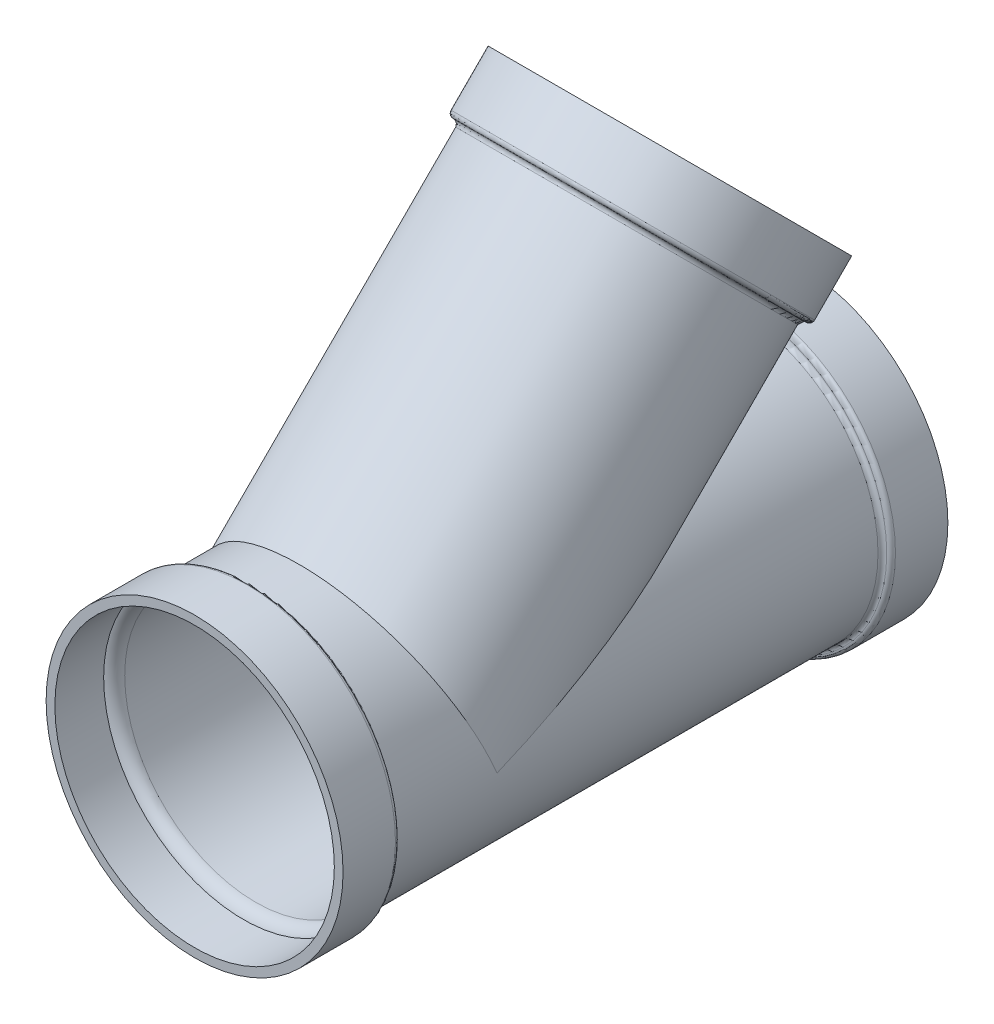
from build123d import *


with BuildPart() as part:
    # Sketch1 → Revolve1 (revolve)
    with BuildSketch(Plane(origin=(0, 0, 0), x_dir=(0, 0, -1), z_dir=(1, 0, 0)), mode=Mode.PRIVATE) as revolve1_sk:
        with BuildLine():
            Line((-439.7375, 215.9), (-363.5375, 215.9))
            ThreePointArc((-363.5375, 215.9), (-359.047371939, 214.040128061), (-357.1875, 209.55))
            ThreePointArc((-357.1875, 209.55), (-355.327628061, 205.059871939), (-350.8375, 203.2))
            Line((-350.8375, 203.2), (350.8375, 203.2))
            ThreePointArc((350.8375, 203.2), (355.327628061, 205.059871939), (357.1875, 209.55))
            ThreePointArc((357.1875, 209.55), (359.047371939, 214.040128061), (363.5375, 215.9))
            Line((363.5375, 215.9), (439.7375, 215.9))
            Line((439.7375, 215.9), (439.7375, 0))
            Line((439.7375, 0), (-439.7375, 0))
            Line((-439.7375, 0), (-439.7375, 215.9))
        make_face()
    revolve(revolve1_sk.sketch.rotate(Axis((0, 0, 168.705111385), (0, 0, -1)), 90), axis=Axis((0, 0, 168.705111385), (0, 0, -1)))  # turned: the seam where the file's is

    # Sketch2 → Revolve2 (revolve)
    with BuildSketch(Plane(origin=(0, 0, 0), x_dir=(0, 0, -1), z_dir=(1, 0, 0)), mode=Mode.PRIVATE) as revolve2_sk:
        with BuildLine():
            Line((98.761112071, 607.289820187), (251.425466129, 454.625466129))
            Line((251.425466129, 454.625466129), (-203.2, 0))
            Line((-203.2, 0), (-346.884097937, 143.684097937))
            Line((-346.884097937, 143.684097937), (44.879575345, 535.447771219))
            ThreePointArc((44.879575345, 535.447771219), (46.739447284, 539.937899279), (44.879575345, 544.42802734))
            ThreePointArc((44.879575345, 544.42802734), (43.019703405, 548.9181554), (44.879575345, 553.408283461))
            Line((44.879575345, 553.408283461), (98.761112071, 607.289820187))
        make_face()
    revolve(revolve2_sk.sketch.rotate(Axis((0, 0, 203.2), (0, 0.707106781, -0.707106781)), 180), axis=Axis((0, 0, 203.2), (0, 0.707106781, -0.707106781)))  # turned: the seam where the file's is

    # Sketch4 → Cut-Revolve1 (revolve, cut)
    with BuildSketch(Plane(origin=(0, 0, 0), x_dir=(0, 0, -1), z_dir=(1, 0, 0)), mode=Mode.PRIVATE) as cut_revolve1_sk:
        with BuildLine():
            Line((-203.2, 0), (251.425466129, 454.625466129))
            Line((251.425466129, 454.625466129), (107.741368192, 598.309564066))
            Line((107.741368192, 598.309564066), (57.579575345, 548.147771219))
            ThreePointArc((57.579575345, 548.147771219), (59.165099845, 536.716506585), (53.859831466, 526.467515098))
            Line((53.859831466, 526.467515098), (-337.903841816, 134.703841816))
            Line((-337.903841816, 134.703841816), (-203.2, 0))
        make_face()
    revolve(cut_revolve1_sk.sketch.rotate(Axis((0, 0, 203.2), (0, 0.707106781, -0.707106781)), 180), axis=Axis((0, 0, 203.2), (0, 0.707106781, -0.707106781)), mode=Mode.SUBTRACT)  # turned: the seam where the file's is

    # Sketch5 → Cut-Revolve2 (revolve, cut)
    with BuildSketch(Plane(origin=(0, 0, 0), x_dir=(0, 0, -1), z_dir=(1, 0, 0)), mode=Mode.PRIVATE) as cut_revolve2_sk:
        with BuildLine():
            Line((-439.7375, 0), (439.7375, 0))
            Line((439.7375, 0), (439.7375, 203.2))
            Line((439.7375, 203.2), (368.798012242, 203.2))
            ThreePointArc((368.798012242, 203.2), (361.836022628, 193.995740133), (350.8375, 190.5))
            Line((350.8375, 190.5), (-350.8375, 190.5))
            ThreePointArc((-350.8375, 190.5), (-361.836022628, 193.995740133), (-368.798012242, 203.2))
            Line((-368.798012242, 203.2), (-439.7375, 203.2))
            Line((-439.7375, 203.2), (-439.7375, 0))
        make_face()
    revolve(cut_revolve2_sk.sketch.rotate(Axis((0, 0, 168.705111385), (0, 0, -1)), 90), axis=Axis((0, 0, 168.705111385), (0, 0, -1)), mode=Mode.SUBTRACT)  # turned: the seam where the file's is


solid = part.part
